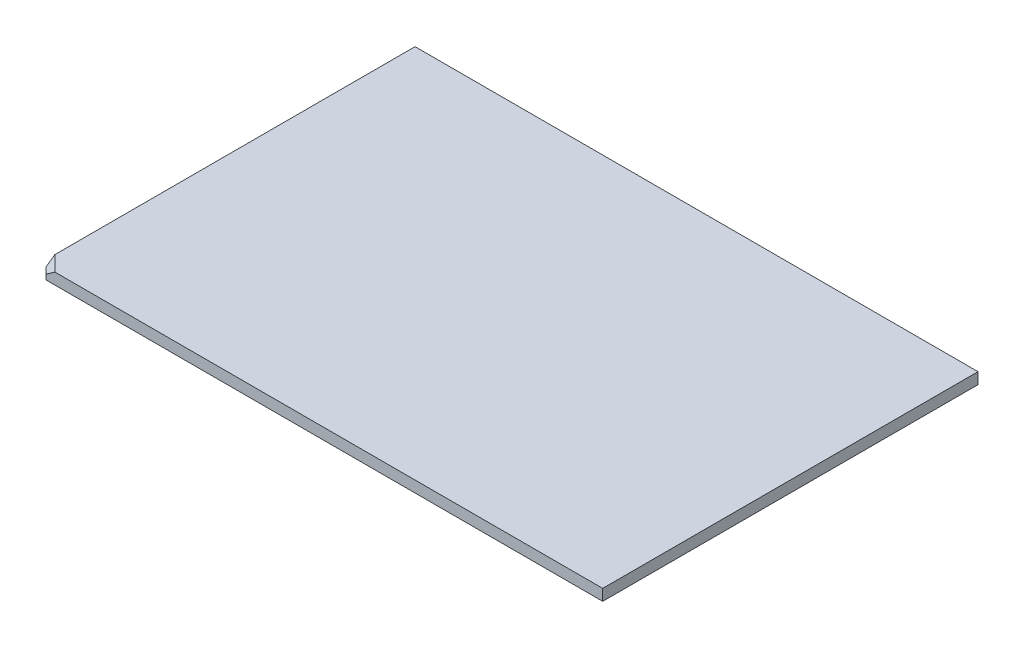
from build123d import *

# Parameters (mm, degrees)
SKETCH1_W           = 450
SKETCH1_H           = 300
BOSS_EXTRUDE1_DEPTH = 9
CHAMFER1_SIZE       = 5
CHAMFER2_SIZE       = 5


with BuildPart() as part:
    # Sketch1 → Boss-Extrude1 (new body)
    with BuildSketch(Plane(origin=(0, 0, 0), x_dir=(1, 0, 0), z_dir=(0, 1, 0))):
        with Locations((198.028733083, 132.54943609)):
            Rectangle(SKETCH1_W, SKETCH1_H)
    extrude(amount=BOSS_EXTRUDE1_DEPTH)

    # Chamfer1
    chamfer1_edges = [part.edges().sort_by_distance(p)[0] for p in [
        (-26.971266917, 4.5, 17.45056391),
    ]]
    chamfer(chamfer1_edges, length=CHAMFER1_SIZE)

    # Chamfer2
    chamfer2_edges = [part.edges().sort_by_distance(p)[0] for p in [
        (-24.471266917, 9, 14.95056391),
    ]]
    chamfer(chamfer2_edges, length=CHAMFER2_SIZE)


solid = part.part
